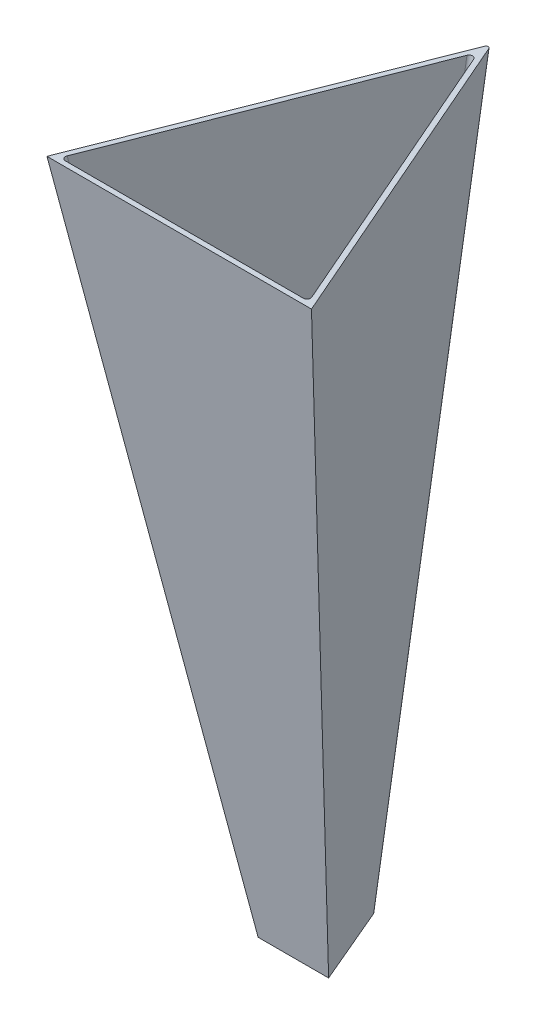
from build123d import *

# Parameters (mm, degrees)
FILLET1_R = 0.5
FILLET3_R = 0.3


with BuildPart() as part:
    # Sketch3 → Loft1 section 0
    with BuildSketch(Plane(origin=(0, 5, 0), x_dir=(1, 0, 0), z_dir=(0, 1, 0))):
        Polygon((4.25, 10.894818804), (-0.529047992, -0.35), (9.029047992, -0.35), align=None)
    # Sketch4 → Loft1 section 1
    with BuildSketch(Plane(origin=(0, 98.205572967, 2.155983202), x_dir=(-0.999633121, -0.000594485, 0.027078956), z_dir=(0, -0.999759103, -0.021948488))):
        Polygon((-5.025697058, 28.570776588), (14.056488149, -13.306873869), (-21.81216364, -14.278750127), align=None)
    loft()

    # Sketch3_411 → Cut-Loft1 section 0
    with BuildSketch(Plane(origin=(0, 5, 0), x_dir=(1, 0, 0), z_dir=(0, 1, 0))):
        Polygon((4.25, 9.105181196), (0.529047992, 0.35), (7.970952008, 0.35), align=None)
    # Sketch4_174 → Cut-Loft1 section 1
    with BuildSketch(Plane(origin=(0, 98.205572967, 2.155983202), x_dir=(-0.999633121, -0.000594485, 0.027078956), z_dir=(0, -0.999759103, -0.021948488))):
        Polygon((-4.977063106, 26.775862609), (12.981432828, -12.635746037), (-20.775027993, -13.550391589), align=None)
    loft(mode=Mode.SUBTRACT)

    # Fillet1
    fillet1_edges = [part.edges().sort_by_distance(p)[0] for p in [
        (-6.05268848, 51.460310962, 7.392787153),
        (14.55268848, 51.460310962, 7.392787153),
        (4.25, 51.898002922, -16.921781459),
    ]]
    fillet(fillet1_edges, radius=FILLET1_R)

    # Fillet3
    fillet3_edges = [part.edges().sort_by_distance(p)[0] for p in [
        (4.25, 51.917707976, -18.714170357),
    ]]
    fillet(fillet3_edges, radius=FILLET3_R)


solid = part.part
